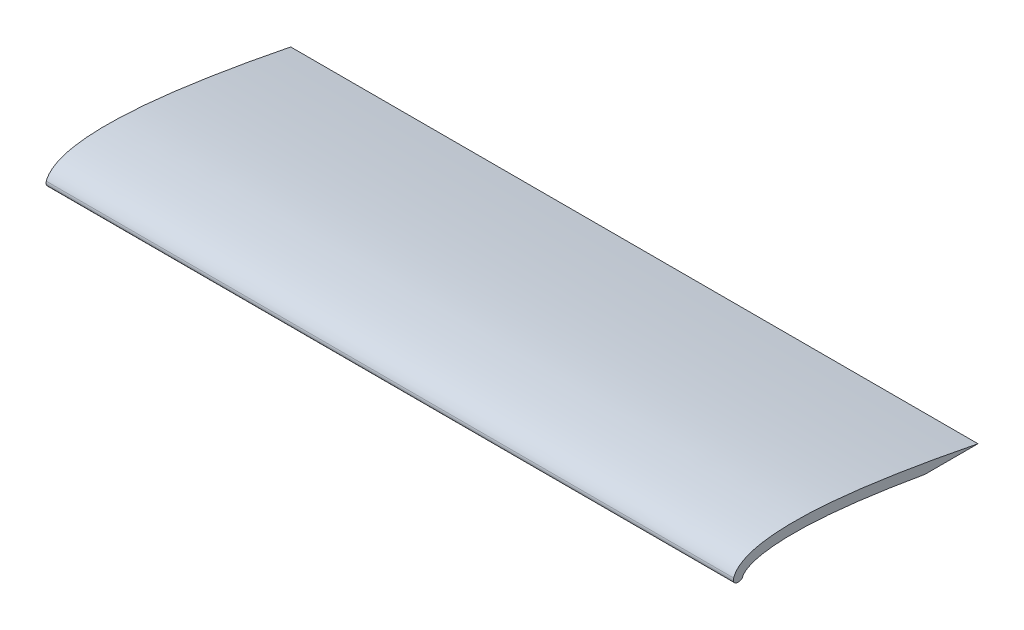
from build123d import *

# Parameters (mm, degrees)
BOSS_EXTRUDE1_DEPTH = 177.8
FILLET1_R           = 1.143


with BuildPart() as part:
    # Sketch1 → Boss-Extrude1 (new body)
    with BuildSketch(Plane(origin=(0, 0, 0), x_dir=(0, 0, -1), z_dir=(1, 0, 0))):
        with BuildLine():
            add(Edge.make_bspline(
                [(0, 0), (0, 12.7), (63.5, 0)],
                knots=[0, 0, 0, 1, 1, 1], degree=2))
            Line((0, 0), (2.54, 0))
            add(Edge.make_bspline(
                [(2.54, 0), (2.543542174, 0.291970761), (2.652908762, 0.705261199), (2.893700113, 1.137187569), (3.567045726, 1.749770153), (4.834908518, 2.413179532), (6.72016171, 3.004506298), (9.814502842, 3.570276806), (15.611303824, 3.906307508), (24.345788638, 3.519882535), (38.440550634, 1.983319347), (49.767711448, 0)],
                knots=[0, 0, 0, 0.046875, 0.09375, 0.15625, 0.21875, 0.28125, 0.34375, 0.4375, 0.5625, 0.6875, 0.889213761, 0.889213761, 0.889213761], degree=2))
            Line((49.767711448, 0), (63.5, 0))
        make_face()
    extrude(amount=BOSS_EXTRUDE1_DEPTH)

    # Fillet1
    fillet1_edges = [part.edges().sort_by_distance(p)[0] for p in [
        (88.9, 0, -2.54),
        (88.9, 0, 0),
    ]]
    fillet(fillet1_edges, radius=FILLET1_R)


solid = part.part
